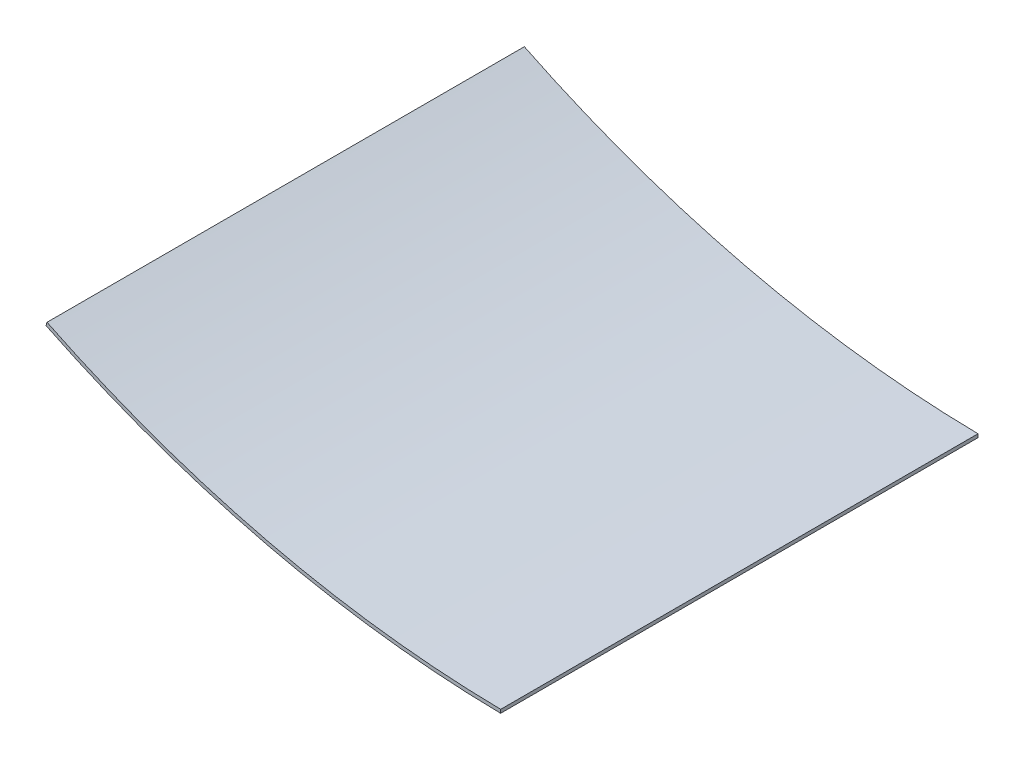
from build123d import *

# Parameters (mm, degrees)
BOSS_EXTRUDE1_DEPTH = 434.6


with BuildPart() as part:
    # Sketch1 → Boss-Extrude1 (new body)
    with BuildSketch(Plane.XY):
        with BuildLine():
            Line((-1e-09, 242.994274124), (-0.044941243, 239.819592205))
            ThreePointArc((-0.044941243, 239.819592205), (-212.474101201, 266.337998302), (-413.99080623, 338.590274786))
            Line((-413.99080623, 338.590274786), (-413.059075646, 341.66879585))
            ThreePointArc((-413.059075646, 341.66879585), (-211.987055097, 269.485951335), (-1e-09, 242.994274124))
        make_face()
    extrude(amount=-BOSS_EXTRUDE1_DEPTH)


solid = part.part
